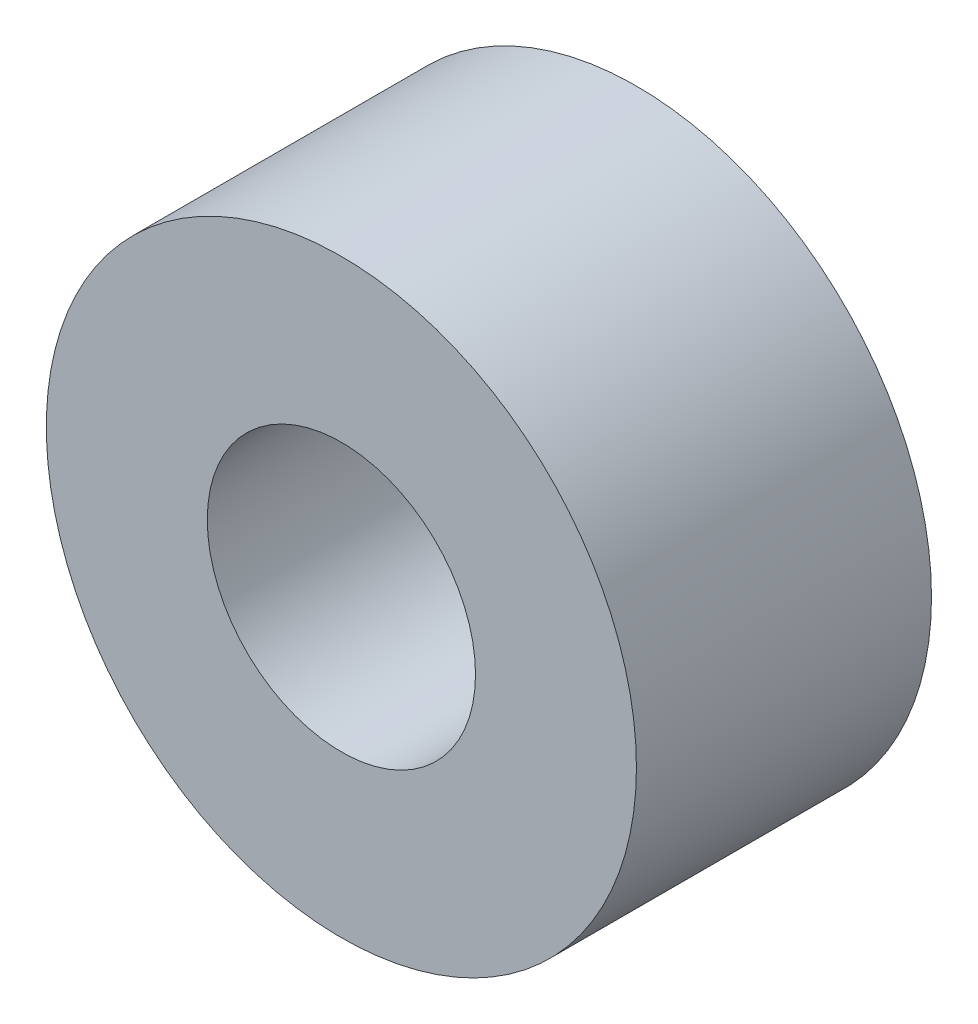
from build123d import *

# Parameters (mm, degrees)
SKETCH1_R           = 5.5
SKETCH1_R_2         = 2.5
BOSS_EXTRUDE1_DEPTH = 5.5


with BuildPart() as part:
    # Sketch1 → Boss-Extrude1 (new body)
    with BuildSketch(Plane.XY):
        Circle(SKETCH1_R)
        Circle(SKETCH1_R_2, mode=Mode.SUBTRACT)
    extrude(amount=BOSS_EXTRUDE1_DEPTH)


solid = part.part
